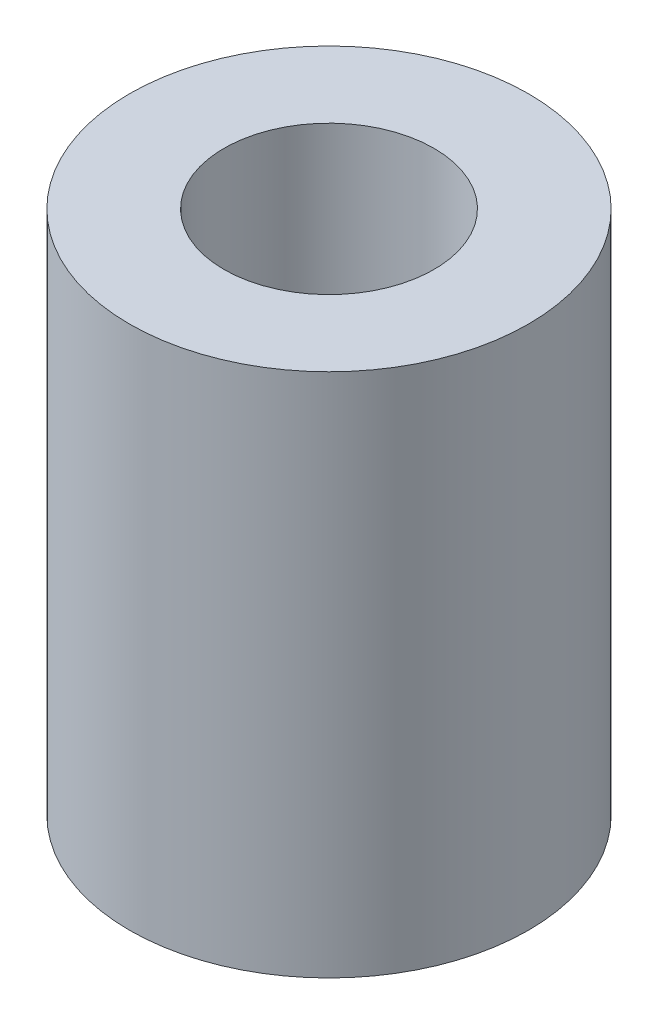
from build123d import *

# Parameters (mm, degrees)
SKETCH1_R           = 9.5
SKETCH1_R_2         = 5
BOSS_EXTRUDE1_DEPTH = 25


with BuildPart() as part:
    # Sketch1 → Boss-Extrude1 (new body)
    with BuildSketch(Plane(origin=(0, 0, 0), x_dir=(1, 0, 0), z_dir=(0, 1, 0))):
        Circle(SKETCH1_R)
        Circle(SKETCH1_R_2, mode=Mode.SUBTRACT)
    extrude(amount=BOSS_EXTRUDE1_DEPTH)


solid = part.part
